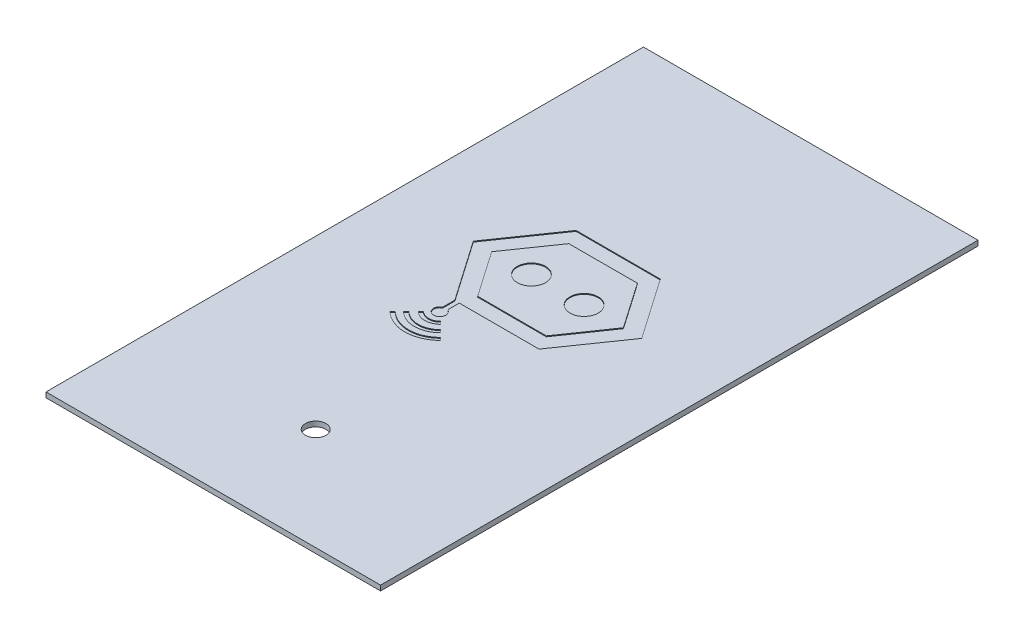
from build123d import *

# Parameters (mm, degrees)
SKETCH1_W                  = 196
SKETCH1_H                  = 350
BOSS_EXTRUDE1_DEPTH        = 3
F_12_0MM_DOWEL_HOLE1_D     = 12
F_12_0MM_DOWEL_HOLE1_DEPTH = 3
CUT_EXTRUDE1_DEPTH         = 0.5


with BuildPart() as part:
    # Sketch1 → Boss-Extrude1 (new body)
    with BuildSketch(Plane(origin=(0, 0, 0), x_dir=(1, 0, 0), z_dir=(0, 1, 0))):
        with Locations((98, 175)):
            Rectangle(SKETCH1_W, SKETCH1_H)
    extrude(amount=BOSS_EXTRUDE1_DEPTH)

    # Ø12.0mm Dowel Hole1
    with Locations(Plane(origin=(0, 3, 0), x_dir=(1, 0, 0), z_dir=(0, 1, 0))):
        with Locations((98, 60)):
            Hole(F_12_0MM_DOWEL_HOLE1_D / 2, depth=F_12_0MM_DOWEL_HOLE1_DEPTH)

    # Sketch8 → Cut-Extrude1 (cut)
    with BuildSketch(Plane(origin=(0, 3, 0), x_dir=(1, 0, 0), z_dir=(0, 1, 0))):
        with BuildLine():
            add(Edge.make_bspline(
                [(71.05659225, 156.0367595), (71.05659225, 157.15759525), (71.7417505, 158.41234325), (72.6707025, 158.9927055)],
                knots=[0, 0, 0, 0, 1, 1, 1, 1], degree=3))
            Line((72.6707025, 158.9927055), (73.1647855, 159.30138625))
            Line((73.1647855, 159.30138625), (73.16901875, 162.8333715))
            Line((73.16901875, 162.8333715), (73.17325225, 166.36535725))
            Line((73.17325225, 166.36535725), (60.91627725, 184.0220725))
            Line((60.91627725, 184.0220725), (48.6592955, 201.67879275))
            Line((48.6592955, 201.67879275), (60.982423, 219.44540475))
            Line((60.982423, 219.44540475), (73.305544, 237.21201025))
            Line((73.305544, 237.21201025), (97.9999935, 237.21201025))
            Line((97.9999935, 237.21201025), (122.69443425, 237.21201025))
            Line((122.69443425, 237.21201025), (135.01748575, 219.44551725))
            Line((135.01748575, 219.44551725), (147.3405285, 201.678839))
            Line((147.3405285, 201.678839), (135.01748575, 183.9122825))
            Line((135.01748575, 183.9122825), (122.6944435, 166.14572925))
            Line((122.6944435, 166.14572925), (99.344963, 166.1410925))
            Line((99.344963, 166.1410925), (75.99548325, 166.1364555))
            Line((75.99548325, 166.1364555), (75.99548325, 162.757854))
            Line((75.99548325, 162.757854), (75.99548325, 159.37925325))
            Line((75.99548325, 159.37925325), (76.538428, 159.031639))
            add(Edge.make_bspline(
                [(76.538428, 159.031639), (77.52104425, 158.402526), (78.20034225, 157.178971), (78.20034225, 156.03819225)],
                knots=[0, 0, 0, 0, 1, 1, 1, 1], degree=3))
            add(Edge.make_bspline(
                [(78.20034225, 156.03819225), (78.20034225, 153.7120825), (75.8544735, 151.956201), (73.64384675, 152.627658)],
                knots=[0, 0, 0, 0, 1, 1, 1, 1], degree=3))
            add(Edge.make_bspline(
                [(73.64384675, 152.627658), (72.1379045, 153.085077), (71.05659225, 154.509859), (71.05659225, 156.0367595)],
                knots=[0, 0, 0, 0, 1, 1, 1, 1], degree=3))
        make_face()
        with BuildLine():
            add(Edge.make_bspline(
                [(136.55098425, 201.72573625), (136.5225145, 201.80235975), (121.242934, 223.84672875), (118.84036725, 227.2774485)],
                knots=[0, 0, 0, 0, 1, 1, 1, 1], degree=3))
            Line((118.84036725, 227.2774485), (118.05274975, 228.40211275))
            Line((118.05274975, 228.40211275), (97.98007025, 228.37988125))
            Line((97.98007025, 228.37988125), (77.907389, 228.35763625))
            Line((77.907389, 228.35763625), (68.661703, 215.0402775))
            add(Edge.make_bspline(
                [(68.661703, 215.0402775), (63.57657, 207.715731), (59.41605, 201.70307475), (59.416103, 201.678819)],
                knots=[0, 0, 0, 0, 1, 1, 1, 1], degree=3))
            add(Edge.make_bspline(
                [(59.416103, 201.678819), (59.4161425, 201.6545635), (63.576742, 195.64190925), (68.66186175, 188.31736075)],
                knots=[0, 0, 0, 0, 1, 1, 1, 1], degree=3))
            Line((68.66186175, 188.31736075), (77.9075345, 175))
            Line((77.9075345, 175), (98, 175))
            Line((98, 175), (118.092461, 175))
            Line((118.092461, 175), (127.33863125, 188.31736075))
            add(Edge.make_bspline(
                [(127.33863125, 188.31736075), (132.42402525, 195.64190925), (136.56958375, 201.67567725), (136.55098425, 201.72573625)],
                knots=[0, 0, 0, 0, 1, 1, 1, 1], degree=3))
        make_face(mode=Mode.SUBTRACT)
        with BuildLine():
            add(Edge.make_bspline(
                [(82.34548325, 210.01013825), (82.903311, 210.02812325), (83.47877975, 210.0239825), (83.6243005, 210.000944)],
                knots=[0, 0, 0, 0, 1, 1, 1, 1], degree=3))
            add(Edge.make_bspline(
                [(83.6243005, 210.000944), (85.55996575, 209.694424), (87.0541075, 208.96582775), (88.3722485, 207.68567425)],
                knots=[0, 0, 0, 0, 1, 1, 1, 1], degree=3))
            add(Edge.make_bspline(
                [(88.3722485, 207.68567425), (89.50828325, 206.582375), (90.274252, 205.2560055), (90.654379, 203.733871)],
                knots=[0, 0, 0, 0, 1, 1, 1, 1], degree=3))
            add(Edge.make_bspline(
                [(90.654379, 203.733871), (90.92787875, 202.63868125), (90.92787875, 200.8953415), (90.654379, 199.8001585)],
                knots=[0, 0, 0, 0, 1, 1, 1, 1], degree=3))
            add(Edge.make_bspline(
                [(90.654379, 199.8001585), (90.288652, 198.3356765), (89.602369, 197.11033675), (88.528723, 196.00483025)],
                knots=[0, 0, 0, 0, 1, 1, 1, 1], degree=3))
            add(Edge.make_bspline(
                [(88.528723, 196.00483025), (87.42542375, 194.86879275), (86.09905425, 194.102828), (84.5769195, 193.72270175)],
                knots=[0, 0, 0, 0, 1, 1, 1, 1], degree=3))
            add(Edge.make_bspline(
                [(84.5769195, 193.72270175), (83.96921125, 193.57093675), (83.542207, 193.528852), (82.6100665, 193.528852)],
                knots=[0, 0, 0, 0, 1, 1, 1, 1], degree=3))
            add(Edge.make_bspline(
                [(82.6100665, 193.528852), (81.67792625, 193.528852), (81.25092175, 193.57093675), (80.6432135, 193.72270175)],
                knots=[0, 0, 0, 0, 1, 1, 1, 1], degree=3))
            add(Edge.make_bspline(
                [(80.6432135, 193.72270175), (79.1045755, 194.1069475), (77.76566475, 194.88516975), (76.6698335, 196.03216025)],
                knots=[0, 0, 0, 0, 1, 1, 1, 1], degree=3))
            add(Edge.make_bspline(
                [(76.6698335, 196.03216025), (75.58705925, 197.16548925), (74.92975475, 198.34258875), (74.56575425, 199.8001585)],
                knots=[0, 0, 0, 0, 1, 1, 1, 1], degree=3))
            add(Edge.make_bspline(
                [(74.56575425, 199.8001585), (74.292248, 200.8953415), (74.292248, 202.63868125), (74.56575425, 203.733871)],
                knots=[0, 0, 0, 0, 1, 1, 1, 1], degree=3))
            add(Edge.make_bspline(
                [(74.56575425, 203.733871), (74.94588125, 205.2560055), (75.71184325, 206.582375), (76.84788475, 207.68567425)],
                knots=[0, 0, 0, 0, 1, 1, 1, 1], degree=3))
            add(Edge.make_bspline(
                [(76.84788475, 207.68567425), (78.4013065, 209.19433525), (80.16446325, 209.9398185), (82.34548325, 210.01013825)],
                knots=[0, 0, 0, 0, 1, 1, 1, 1], degree=3))
        make_face()
        with BuildLine():
            add(Edge.make_bspline(
                [(113.213541, 210.01013825), (113.77137075, 210.02812325), (114.3468395, 210.0239825), (114.49236025, 210.000944)],
                knots=[0, 0, 0, 0, 1, 1, 1, 1], degree=3))
            add(Edge.make_bspline(
                [(114.49236025, 210.000944), (116.4280235, 209.694424), (117.922166, 208.96582775), (119.24030675, 207.68567425)],
                knots=[0, 0, 0, 0, 1, 1, 1, 1], degree=3))
            add(Edge.make_bspline(
                [(119.24030675, 207.68567425), (120.37634425, 206.582375), (121.142309, 205.2560055), (121.52243525, 203.733871)],
                knots=[0, 0, 0, 0, 1, 1, 1, 1], degree=3))
            add(Edge.make_bspline(
                [(121.52243525, 203.733871), (121.7959385, 202.63868125), (121.7959385, 200.8953415), (121.52243525, 199.8001585)],
                knots=[0, 0, 0, 0, 1, 1, 1, 1], degree=3))
            add(Edge.make_bspline(
                [(121.52243525, 199.8001585), (121.156707, 198.3356765), (120.47042875, 197.11033675), (119.39678275, 196.00483025)],
                knots=[0, 0, 0, 0, 1, 1, 1, 1], degree=3))
            add(Edge.make_bspline(
                [(119.39678275, 196.00483025), (118.29348425, 194.86879275), (116.96711475, 194.102828), (115.44497925, 193.72270175)],
                knots=[0, 0, 0, 0, 1, 1, 1, 1], degree=3))
            add(Edge.make_bspline(
                [(115.44497925, 193.72270175), (114.837269, 193.57093675), (114.41026325, 193.528852), (113.47812425, 193.528852)],
                knots=[0, 0, 0, 0, 1, 1, 1, 1], degree=3))
            add(Edge.make_bspline(
                [(113.47812425, 193.528852), (112.54598475, 193.528852), (112.118979, 193.57093675), (111.51126875, 193.72270175)],
                knots=[0, 0, 0, 0, 1, 1, 1, 1], degree=3))
            add(Edge.make_bspline(
                [(111.51126875, 193.72270175), (109.9726365, 194.1069475), (108.6337205, 194.88516975), (107.5378925, 196.03216025)],
                knots=[0, 0, 0, 0, 1, 1, 1, 1], degree=3))
            add(Edge.make_bspline(
                [(107.5378925, 196.03216025), (106.455115, 197.16548925), (105.797814, 198.34258875), (105.43381275, 199.8001585)],
                knots=[0, 0, 0, 0, 1, 1, 1, 1], degree=3))
            add(Edge.make_bspline(
                [(105.43381275, 199.8001585), (105.1603095, 200.8953415), (105.1603095, 202.63868125), (105.43381275, 203.733871)],
                knots=[0, 0, 0, 0, 1, 1, 1, 1], degree=3))
            add(Edge.make_bspline(
                [(105.43381275, 203.733871), (105.813939, 205.2560055), (106.57990375, 206.582375), (107.71594125, 207.68567425)],
                knots=[0, 0, 0, 0, 1, 1, 1, 1], degree=3))
            add(Edge.make_bspline(
                [(107.71594125, 207.68567425), (109.26936675, 209.19433525), (111.0325205, 209.9398185), (113.213541, 210.01013825)],
                knots=[0, 0, 0, 0, 1, 1, 1, 1], degree=3))
        make_face()
        with BuildLine():
            add(Edge.make_bspline(
                [(77.23020775, 143.5476515), (79.5899405, 144.054316), (81.501039, 145.000144), (83.280243, 146.5418895)],
                knots=[0, 0, 0, 0, 1, 1, 1, 1], degree=3))
            Line((83.280243, 146.5418895), (83.994512, 147.160834))
            Line((83.994512, 147.160834), (84.76425775, 146.387509))
            Line((84.76425775, 146.387509), (85.53399675, 145.614183))
            Line((85.53399675, 145.614183), (84.97602375, 145.10793975))
            add(Edge.make_bspline(
                [(84.97602375, 145.10793975), (82.5058405, 142.8667675), (79.580184, 141.55467875), (76.21596725, 141.17926025)],
                knots=[0, 0, 0, 0, 1, 1, 1, 1], degree=3))
            add(Edge.make_bspline(
                [(76.21596725, 141.17926025), (72.26491125, 140.73835325), (68.1263185, 141.99740075), (64.93635625, 144.610758)],
                knots=[0, 0, 0, 0, 1, 1, 1, 1], degree=3))
            add(Edge.make_bspline(
                [(64.93635625, 144.610758), (64.5917035, 144.89311325), (64.23245875, 145.21029725), (64.138029, 145.315612)],
                knots=[0, 0, 0, 0, 1, 1, 1, 1], degree=3))
            Line((64.138029, 145.315612), (63.96633425, 145.50709475))
            Line((63.96633425, 145.50709475), (64.72896275, 146.2697165))
            Line((64.72896275, 146.2697165), (65.49157775, 147.032339))
            Line((65.49157775, 147.032339), (66.010611, 146.58090225))
            add(Edge.make_bspline(
                [(66.010611, 146.58090225), (67.31365075, 145.44755175), (69.0063755, 144.46717975), (70.5274255, 143.96490725)],
                knots=[0, 0, 0, 0, 1, 1, 1, 1], degree=3))
            add(Edge.make_bspline(
                [(70.5274255, 143.96490725), (71.96572025, 143.489963), (72.91536275, 143.3488185), (74.6725665, 143.3488185)],
                knots=[0, 0, 0, 0, 1, 1, 1, 1], degree=3))
            add(Edge.make_bspline(
                [(74.6725665, 143.3488185), (76.03292175, 143.3488185), (76.45811375, 143.38187275), (77.23020775, 143.5476515)],
                knots=[0, 0, 0, 0, 1, 1, 1, 1], degree=3))
        make_face()
        with BuildLine():
            add(Edge.make_bspline(
                [(70.2790875, 150.949713), (72.87973, 148.8331435), (76.80790625, 148.87756575), (79.27759975, 151.05147425)],
                knots=[0, 0, 0, 0, 1, 1, 1, 1], degree=3))
            add(Edge.make_bspline(
                [(79.27759975, 151.05147425), (79.50035925, 151.247555), (79.6972025, 151.4079865), (79.71502225, 151.4079865)],
                knots=[0, 0, 0, 0, 1, 1, 1, 1], degree=3))
            add(Edge.make_bspline(
                [(79.71502225, 151.4079865), (79.732842, 151.4079865), (80.09417675, 151.05961825), (80.51798625, 150.6338355)],
                knots=[0, 0, 0, 0, 1, 1, 1, 1], degree=3))
            Line((80.51798625, 150.6338355), (81.28855225, 149.859685))
            Line((81.28855225, 149.859685), (80.78073075, 149.43014))
            add(Edge.make_bspline(
                [(80.78073075, 149.43014), (79.70705175, 148.52195775), (78.385028, 147.83715), (76.98377475, 147.46331425)],
                knots=[0, 0, 0, 0, 1, 1, 1, 1], degree=3))
            add(Edge.make_bspline(
                [(76.98377475, 147.46331425), (76.232186, 147.26280175), (75.95565025, 147.23494625), (74.716666, 147.23494625)],
                knots=[0, 0, 0, 0, 1, 1, 1, 1], degree=3))
            add(Edge.make_bspline(
                [(74.716666, 147.23494625), (73.47767525, 147.23494625), (73.20113925, 147.26280175), (72.44955075, 147.46331425)],
                knots=[0, 0, 0, 0, 1, 1, 1, 1], degree=3))
            add(Edge.make_bspline(
                [(72.44955075, 147.46331425), (71.44513275, 147.731279), (70.3126235, 148.2427695), (69.48578075, 148.8018855)],
                knots=[0, 0, 0, 0, 1, 1, 1, 1], degree=3))
            add(Edge.make_bspline(
                [(69.48578075, 148.8018855), (68.8494645, 149.2321655), (68.3225665, 149.68549925), (68.3225665, 149.80269725)],
                knots=[0, 0, 0, 0, 1, 1, 1, 1], degree=3))
            add(Edge.make_bspline(
                [(68.3225665, 149.80269725), (68.3225665, 149.84278875), (68.6572975, 150.2031175), (69.06641625, 150.6034295)],
                knots=[0, 0, 0, 0, 1, 1, 1, 1], degree=3))
            Line((69.06641625, 150.6034295), (69.81027225, 151.33126925))
            Line((69.81027225, 151.33126925), (70.2790875, 150.949713))
        make_face()
        with BuildLine():
            add(Edge.make_bspline(
                [(74.62846725, 135.53358975), (69.80542375, 135.53358975), (64.906584, 137.32517475), (61.1788165, 140.4523525)],
                knots=[0, 0, 0, 0, 1, 1, 1, 1], degree=3))
            add(Edge.make_bspline(
                [(61.1788165, 140.4523525), (60.7179985, 140.83892475), (60.26398675, 141.24111), (60.16990075, 141.346096)],
                knots=[0, 0, 0, 0, 1, 1, 1, 1], degree=3))
            Line((60.16990075, 141.346096), (59.99882125, 141.53698025))
            Line((59.99882125, 141.53698025), (60.7412155, 142.2832475))
            add(Edge.make_bspline(
                [(60.7412155, 142.2832475), (61.14952725, 142.69369425), (61.50432675, 143.028105), (61.5296475, 143.02638325)],
                knots=[0, 0, 0, 0, 1, 1, 1, 1], degree=3))
            add(Edge.make_bspline(
                [(61.5296475, 143.02638325), (61.55497475, 143.0246635), (61.98616625, 142.66911975), (62.48784925, 142.2362925)],
                knots=[0, 0, 0, 0, 1, 1, 1, 1], degree=3))
            add(Edge.make_bspline(
                [(62.48784925, 142.2362925), (66.826824, 138.4928685), (72.6097625, 136.98039825), (78.288541, 138.103777)],
                knots=[0, 0, 0, 0, 1, 1, 1, 1], degree=3))
            add(Edge.make_bspline(
                [(78.288541, 138.103777), (81.51028625, 138.741105), (84.32246975, 140.1242925), (86.89239425, 142.33562975)],
                knots=[0, 0, 0, 0, 1, 1, 1, 1], degree=3))
            add(Edge.make_bspline(
                [(86.89239425, 142.33562975), (87.44866075, 142.81428), (87.91412225, 143.205903), (87.92675625, 143.205903)],
                knots=[0, 0, 0, 0, 1, 1, 1, 1], degree=3))
            add(Edge.make_bspline(
                [(87.92675625, 143.205903), (87.93939, 143.205903), (88.28449275, 142.8693895), (88.693651, 142.45809475)],
                knots=[0, 0, 0, 0, 1, 1, 1, 1], degree=3))
            Line((88.693651, 142.45809475), (89.43757325, 141.7102855))
            Line((89.43757325, 141.7102855), (89.176767, 141.43435175))
            add(Edge.make_bspline(
                [(89.176767, 141.43435175), (89.03332975, 141.28258875), (88.538936, 140.84140975), (88.07812425, 140.453956)],
                knots=[0, 0, 0, 0, 1, 1, 1, 1], degree=3))
            add(Edge.make_bspline(
                [(88.07812425, 140.453956), (84.3622895, 137.32968525), (79.4527275, 135.53358975), (74.62846725, 135.53358975)],
                knots=[0, 0, 0, 0, 1, 1, 1, 1], degree=3))
        make_face()
    extrude(amount=-CUT_EXTRUDE1_DEPTH, mode=Mode.SUBTRACT)


solid = part.part
